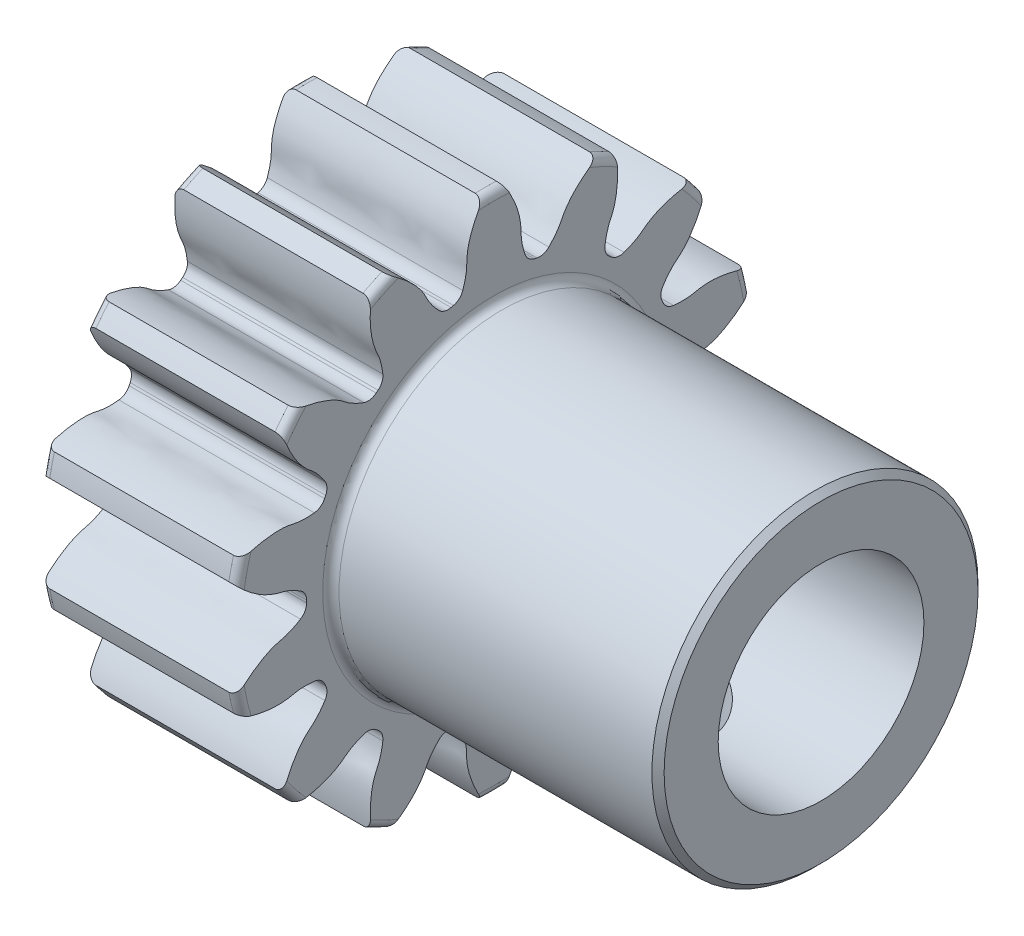
from build123d import *

# Parameters (mm, degrees)
SKETCH1_W                  = 4.7498
SKETCH1_H                  = 6.35
CUT_EXTRUDE1_DEPTH         = 5.7498
CUT_EXTRUDE2_DEPTH         = 5.7498001
CUT_EXTRUDE3_DEPTH         = 5.7498001
CUT_EXTRUDE4_DEPTH         = 5.7498001
CUT_EXTRUDE5_DEPTH         = 5.7498001
CUT_EXTRUDE6_DEPTH         = 5.7498001
CUT_EXTRUDE7_DEPTH         = 5.7498001
CUT_EXTRUDE8_DEPTH         = 5.7498001
CUT_EXTRUDE9_DEPTH         = 5.7498001
CUT_EXTRUDE10_DEPTH        = 5.7498001
CUT_EXTRUDE11_DEPTH        = 5.7498001
CUT_EXTRUDE12_DEPTH        = 5.7498001
CUT_EXTRUDE13_DEPTH        = 5.7498001
CUT_EXTRUDE14_DEPTH        = 5.7498001
SKETCH16_W                 = 7.9502
SKETCH16_H                 = 3.9624
M3_5_CLEARANCE_HOLE1_D     = 3.9624
M3_5_CLEARANCE_HOLE1_DEPTH = 12.7
CHAMFER1_SIZE              = 0.14859
FILLET1_R                  = 0.1984375
FILLET2_R                  = 0.3095625
SKETCH19_R                 = 2.5
SHAFT_WIDENING_DEPTH       = 13.7000001
SKETCH20_R                 = 1.27
SET_SCREW_HOLE_DEPTH       = 7.3500001


with BuildPart() as part:
    # Sketch1 → Revolve1 (revolve)
    with BuildSketch(Plane.XY):
        with Locations((0, 3.175)):
            Rectangle(SKETCH1_W, SKETCH1_H)
    revolve(axis=Axis((-2.3749, 0, 0), (1, 0, 0)))

    # Sketch2 → Cut-Extrude1 (cut, through all)
    with BuildSketch(Plane(origin=(2.3749, 0, 0), x_dir=(0, 0, -1), z_dir=(1, 0, 0))):
        with BuildLine():
            ThreePointArc((2.521994598, 5.827696221), (1.413007931, 6.190792242), (0.256304009, 6.344825313))
            add(Edge.make_bspline(
                [(0.816869379, 4.479071123), (0.796906852, 4.535641399), (0.776369435, 4.59201523), (0.757224936, 4.648867554), (0.704497418, 4.805449455), (0.660288083, 4.96993855), (0.661280004, 5.135156887), (0.662293342, 5.303942526), (0.638573392, 5.474877258), (0.58971746, 5.63644061), (0.536967085, 5.810882629), (0.463788824, 5.979864297), (0.376808301, 6.140011132), (0.339002487, 6.209618456), (0.29866827, 6.277894538), (0.256304009, 6.344825313)],
                knots=[-0.000178466, -0.000178466, -0.000178466, -0.000178466, 0, 0, 0, 0.000495664, 0.000495664, 0.000495664, 0.000997325, 0.000997325, 0.000997325, 0.001535785, 0.001535785, 0.001535785, 0.001769073, 0.001769073, 0.001769073, 0.001769073], degree=3))
            ThreePointArc((0.816869379, 4.479071123), (1.013126686, 4.438798038), (1.207422247, 4.389929979))
            add(Edge.make_bspline(
                [(1.207422247, 4.389929979), (1.249952785, 4.432236621), (1.292916047, 4.474116836), (1.334831943, 4.517032524), (1.450276136, 4.635230329), (1.561476514, 4.764248171), (1.632268374, 4.913535127), (1.704588732, 5.066045404), (1.80012547, 5.209760576), (1.914242855, 5.334126332), (2.037456856, 5.46840563), (2.176706589, 5.588901995), (2.32455844, 5.695449873), (2.388821788, 5.741760577), (2.454785543, 5.785774841), (2.521994598, 5.827696221)],
                knots=[-0.000178466, -0.000178466, -0.000178466, -0.000178466, 0, 0, 0, 0.000495664, 0.000495664, 0.000495664, 0.000997325, 0.000997325, 0.000997325, 0.001535785, 0.001535785, 0.001535785, 0.00176905, 0.00176905, 0.00176905, 0.00176905], degree=3))
        make_face()
    extrude(amount=-CUT_EXTRUDE1_DEPTH, mode=Mode.SUBTRACT)

    # Sketch3 → Cut-Extrude2 (cut, through all)
    with BuildSketch(Plane(origin=(2.3749, 0, 0), x_dir=(0, 0, -1), z_dir=(1, 0, 0))):
        with BuildLine():
            ThreePointArc((4.800781245, 4.156320421), (3.959160242, 4.964629914), (2.983838464, 5.605283938))
            add(Edge.make_bspline(
                [(2.983838464, 5.605283938), (2.992967169, 5.526600229), (2.999683161, 5.447585244), (3.003543536, 5.368467883), (3.014352941, 5.14693203), (2.999753258, 4.9221841), (2.955789501, 4.704785468), (2.933787316, 4.595985738), (2.898383378, 4.488724906), (2.848665705, 4.389479601), (2.782882496, 4.258164633), (2.740075221, 4.11427691), (2.715468513, 3.969482016), (2.709284574, 3.933093448), (2.703868729, 3.8965643), (2.699304131, 3.859937351), (2.691885429, 3.800408689), (2.685929314, 3.740706772), (2.679370006, 3.681077298)],
                knots=[-0.000236251, -0.000236251, -0.000236251, -0.000236251, 0, 0, 0, 0.000665398, 0.000665398, 0.000665398, 0.000998416, 0.000998416, 0.000998416, 0.001440378, 0.001440378, 0.001440378, 0.001550407, 0.001550407, 0.001550407, 0.001729205, 0.001729205, 0.001729205, 0.001729205], degree=3))
            ThreePointArc((2.679370006, 3.681077298), (2.838717893, 3.559639648), (2.992569089, 3.431309364))
            add(Edge.make_bspline(
                [(2.992569089, 3.431309364), (3.049243943, 3.450973023), (3.106123649, 3.470064732), (3.162508986, 3.490543805), (3.317804716, 3.546946989), (3.473971538, 3.614940013), (3.602525983, 3.718727476), (3.733856103, 3.82475586), (3.882287405, 3.912786919), (4.039063896, 3.975322915), (4.208337479, 4.042843831), (4.386078566, 4.090989109), (4.565517872, 4.122834916), (4.64351061, 4.136676598), (4.722038973, 4.147711478), (4.800781245, 4.156320421)],
                knots=[-0.000178466, -0.000178466, -0.000178466, -0.000178466, 0, 0, 0, 0.000495664, 0.000495664, 0.000495664, 0.000997325, 0.000997325, 0.000997325, 0.001535785, 0.001535785, 0.001535785, 0.001769052, 0.001769052, 0.001769052, 0.001769052], degree=3))
        make_face()
    extrude(amount=-CUT_EXTRUDE2_DEPTH, mode=Mode.SUBTRACT)

    # Sketch4 → Cut-Extrude3 (cut, through all)
    with BuildSketch(Plane(origin=(2.3749, 0, 0), x_dir=(0, 0, -1), z_dir=(1, 0, 0))):
        with BuildLine():
            ThreePointArc((6.128714288, 1.661734387), (5.721152311, 2.755161743), (5.120387116, 3.755547334))
            add(Edge.make_bspline(
                [(5.120387116, 3.755547334), (5.094472214, 3.680694965), (5.066239797, 3.606590964), (5.035390138, 3.533633731), (4.949008271, 3.3293468), (4.838339939, 3.133190476), (4.704404231, 2.956396236), (4.637374513, 2.867917456), (4.558937937, 2.786639979), (4.471082938, 2.718794739), (4.354838885, 2.629026306), (4.253840319, 2.517961328), (4.168846292, 2.398182086), (4.147486347, 2.36808023), (4.126757436, 2.337518452), (4.106753037, 2.306499216), (4.0742405, 2.256084599), (4.042970534, 2.204879291), (4.011188543, 2.154000969)],
                knots=[-0.000236253, -0.000236253, -0.000236253, -0.000236253, 0, 0, 0, 0.000665398, 0.000665398, 0.000665398, 0.000998416, 0.000998416, 0.000998416, 0.001440378, 0.001440378, 0.001440378, 0.001550407, 0.001550407, 0.001550407, 0.001729205, 0.001729205, 0.001729205, 0.001729205], degree=3))
            ThreePointArc((4.011188543, 2.154000969), (4.102066207, 1.97545097), (4.185000921, 1.793075847))
            add(Edge.make_bspline(
                [(4.185000921, 1.793075847), (4.244594942, 1.786201894), (4.304125369, 1.77872375), (4.363812339, 1.772710076), (4.52820138, 1.756147298), (4.698403893, 1.74964865), (4.859259138, 1.78738024), (5.02358748, 1.82592651), (5.195514707, 1.840837825), (5.363898796, 1.829158041), (5.545705252, 1.816547229), (5.726733892, 1.782805658), (5.902220498, 1.733641942), (5.978495207, 1.712273085), (6.054034673, 1.688142989), (6.128714288, 1.661734387)],
                knots=[-0.000178466, -0.000178466, -0.000178466, -0.000178466, 0, 0, 0, 0.000495664, 0.000495664, 0.000495664, 0.000997325, 0.000997325, 0.000997325, 0.001535785, 0.001535785, 0.001535785, 0.001769073, 0.001769073, 0.001769073, 0.001769073], degree=3))
        make_face()
    extrude(amount=-CUT_EXTRUDE3_DEPTH, mode=Mode.SUBTRACT)

    # Sketch5 → Cut-Extrude4 (cut, through all)
    with BuildSketch(Plane(origin=(2.3749, 0, 0), x_dir=(0, 0, -1), z_dir=(1, 0, 0))):
        with BuildLine():
            ThreePointArc((6.242780303, -1.161978522), (6.35, 0), (6.242780303, 1.161978522))
            add(Edge.make_bspline(
                [(6.242780303, 1.161978522), (6.186954558, 1.105782923), (6.129365507, 1.051267112), (6.069915968, 0.998920081), (5.903451817, 0.852343603), (5.718634057, 0.723630052), (5.521254007, 0.622456472), (5.422472815, 0.57182295), (5.316538926, 0.532626829), (5.20794736, 0.509619235), (5.064266024, 0.479177076), (4.925080173, 0.422932624), (4.796532934, 0.351892782), (4.764227583, 0.33403968), (4.732291221, 0.315498407), (4.700809139, 0.296230624), (4.649642272, 0.264915285), (4.599251857, 0.232348426), (4.548541995, 0.200298332)],
                knots=[-0.000236275, -0.000236275, -0.000236275, -0.000236275, 0, 0, 0, 0.000665398, 0.000665398, 0.000665398, 0.000998416, 0.000998416, 0.000998416, 0.001440378, 0.001440378, 0.001440378, 0.001550407, 0.001550407, 0.001550407, 0.001729205, 0.001729205, 0.001729205, 0.001729205], degree=3))
            ThreePointArc((4.548541995, 0.200298332), (4.55295, 0), (4.548541995, -0.200298332))
            add(Edge.make_bspline(
                [(4.548541995, -0.200298332), (4.599251857, -0.232348426), (4.649642272, -0.264915285), (4.700809139, -0.296230624), (4.841732227, -0.382478904), (4.992259735, -0.462182085), (5.153556426, -0.497979573), (5.318335746, -0.534549979), (5.479706602, -0.595711777), (5.626347756, -0.679294017), (5.784678087, -0.769538831), (5.933139336, -0.878484319), (6.069915968, -0.998920081), (6.129365507, -1.051267112), (6.186954558, -1.105782923), (6.242780303, -1.161978522)],
                knots=[-0.000178466, -0.000178466, -0.000178466, -0.000178466, 0, 0, 0, 0.000495664, 0.000495664, 0.000495664, 0.000997325, 0.000997325, 0.000997325, 0.001535785, 0.001535785, 0.001535785, 0.001769073, 0.001769073, 0.001769073, 0.001769073], degree=3))
        make_face()
    extrude(amount=-CUT_EXTRUDE4_DEPTH, mode=Mode.SUBTRACT)

    # Sketch6 → Cut-Extrude5 (cut, through all)
    with BuildSketch(Plane(origin=(2.3749, 0, 0), x_dir=(0, 0, -1), z_dir=(1, 0, 0))):
        with BuildLine():
            ThreePointArc((5.120387116, -3.755547334), (5.721152311, -2.755161743), (6.128714288, -1.661734387))
            add(Edge.make_bspline(
                [(6.128714288, -1.661734387), (6.054034673, -1.688142989), (5.978495207, -1.712273085), (5.902220498, -1.733641942), (5.68864433, -1.793476697), (5.466282565, -1.829254178), (5.244551714, -1.834768431), (5.133583873, -1.837528104), (5.021134177, -1.826879597), (4.913313937, -1.800492608), (4.770653168, -1.76557905), (4.620847496, -1.755863074), (4.474207404, -1.764093203), (4.437355117, -1.766161526), (4.400536693, -1.769009967), (4.363812339, -1.772710076), (4.304125369, -1.77872375), (4.244594942, -1.786201894), (4.185000921, -1.793075847)],
                knots=[-0.000236275, -0.000236275, -0.000236275, -0.000236275, 0, 0, 0, 0.000665398, 0.000665398, 0.000665398, 0.000998416, 0.000998416, 0.000998416, 0.001440378, 0.001440378, 0.001440378, 0.001550407, 0.001550407, 0.001550407, 0.001729205, 0.001729205, 0.001729205, 0.001729205], degree=3))
            ThreePointArc((4.185000921, -1.793075847), (4.102066207, -1.97545097), (4.011188543, -2.154000969))
            add(Edge.make_bspline(
                [(4.011188543, -2.154000969), (4.042970534, -2.204879291), (4.0742405, -2.256084599), (4.106753037, -2.306499216), (4.196298627, -2.445350468), (4.29733731, -2.582471991), (4.42712866, -2.684708424), (4.559722392, -2.789152289), (4.678575401, -2.914273355), (4.77442954, -3.053203563), (4.877924482, -3.203208287), (4.96441377, -3.365779702), (5.035390138, -3.533633731), (5.066239797, -3.606590964), (5.094472214, -3.680694965), (5.120387116, -3.755547334)],
                knots=[-0.000178466, -0.000178466, -0.000178466, -0.000178466, 0, 0, 0, 0.000495664, 0.000495664, 0.000495664, 0.000997325, 0.000997325, 0.000997325, 0.001535785, 0.001535785, 0.001535785, 0.001769051, 0.001769051, 0.001769051, 0.001769051], degree=3))
        make_face()
    extrude(amount=-CUT_EXTRUDE5_DEPTH, mode=Mode.SUBTRACT)

    # Sketch7 → Cut-Extrude6 (cut, through all)
    with BuildSketch(Plane(origin=(2.3749, 0, 0), x_dir=(0, 0, -1), z_dir=(1, 0, 0))):
        with BuildLine():
            ThreePointArc((2.983838464, -5.605283938), (3.959160242, -4.964629914), (4.800781245, -4.156320421))
            add(Edge.make_bspline(
                [(4.800781245, -4.156320421), (4.722038973, -4.147711478), (4.64351061, -4.136676598), (4.565517872, -4.122834916), (4.347131067, -4.084076942), (4.131266772, -4.019832184), (3.929101633, -3.928594943), (3.827925686, -3.882934181), (3.731232224, -3.824550114), (3.64553843, -3.753994809), (3.532153943, -3.660640593), (3.401399301, -3.586888555), (3.265710224, -3.530678894), (3.23161005, -3.51655278), (3.197201903, -3.503144222), (3.162508986, -3.490543805), (3.106123649, -3.470064732), (3.049243943, -3.450973023), (2.992569089, -3.431309364)],
                knots=[-0.000236252, -0.000236252, -0.000236252, -0.000236252, 0, 0, 0, 0.000665398, 0.000665398, 0.000665398, 0.000998416, 0.000998416, 0.000998416, 0.001440378, 0.001440378, 0.001440378, 0.001550407, 0.001550407, 0.001550407, 0.001729205, 0.001729205, 0.001729205, 0.001729205], degree=3))
            ThreePointArc((2.992569089, -3.431309364), (2.838717893, -3.559639648), (2.679370006, -3.681077298))
            add(Edge.make_bspline(
                [(2.679370006, -3.681077298), (2.685929314, -3.740706772), (2.691885429, -3.800408689), (2.699304131, -3.859937351), (2.719736619, -4.023890381), (2.751274528, -4.191271646), (2.823853768, -4.339697846), (2.898000098, -4.491328781), (2.950794962, -4.655627354), (2.976877, -4.822388699), (3.005038109, -5.002443057), (3.012425172, -5.186441137), (3.003543536, -5.368467883), (2.999683161, -5.447585244), (2.992967169, -5.526600229), (2.983838464, -5.605283938)],
                knots=[-0.000178466, -0.000178466, -0.000178466, -0.000178466, 0, 0, 0, 0.000495664, 0.000495664, 0.000495664, 0.000997325, 0.000997325, 0.000997325, 0.001535785, 0.001535785, 0.001535785, 0.001769051, 0.001769051, 0.001769051, 0.001769051], degree=3))
        make_face()
    extrude(amount=-CUT_EXTRUDE6_DEPTH, mode=Mode.SUBTRACT)

    # Sketch8 → Cut-Extrude7 (cut, through all)
    with BuildSketch(Plane(origin=(2.3749, 0, 0), x_dir=(0, 0, -1), z_dir=(1, 0, 0))):
        with BuildLine():
            ThreePointArc((0.256304009, -6.344825313), (1.413007931, -6.190792242), (2.521994598, -5.827696221))
            add(Edge.make_bspline(
                [(2.521994598, -5.827696221), (2.454785543, -5.785774841), (2.388821788, -5.741760577), (2.32455844, -5.695449873), (2.144615182, -5.56577566), (1.978002927, -5.414233126), (1.835444787, -5.244315046), (1.76409987, -5.159277523), (1.702313969, -5.064721575), (1.655719328, -4.963972298), (1.594068312, -4.830667371), (1.50826226, -4.707486768), (1.410399084, -4.597970329), (1.385804979, -4.570447629), (1.360622065, -4.5434378), (1.334831943, -4.517032524), (1.292916047, -4.474116836), (1.249952785, -4.432236621), (1.207422247, -4.389929979)],
                knots=[-0.000236253, -0.000236253, -0.000236253, -0.000236253, 0, 0, 0, 0.000665398, 0.000665398, 0.000665398, 0.000998416, 0.000998416, 0.000998416, 0.001440378, 0.001440378, 0.001440378, 0.001550407, 0.001550407, 0.001550407, 0.001729205, 0.001729205, 0.001729205, 0.001729205], degree=3))
            ThreePointArc((1.207422247, -4.389929979), (1.013126686, -4.438798038), (0.816869379, -4.479071123))
            add(Edge.make_bspline(
                [(0.816869379, -4.479071123), (0.796906852, -4.535641399), (0.776369435, -4.59201523), (0.757224936, -4.648867554), (0.704497418, -4.805449455), (0.660288083, -4.96993855), (0.661280004, -5.135156887), (0.662293342, -5.303942526), (0.638573392, -5.474877258), (0.58971746, -5.63644061), (0.536967085, -5.810882629), (0.463788824, -5.979864297), (0.376808301, -6.140011132), (0.339002487, -6.209618456), (0.29866827, -6.277894538), (0.256304009, -6.344825313)],
                knots=[-0.000178466, -0.000178466, -0.000178466, -0.000178466, 0, 0, 0, 0.000495664, 0.000495664, 0.000495664, 0.000997325, 0.000997325, 0.000997325, 0.001535785, 0.001535785, 0.001535785, 0.001769073, 0.001769073, 0.001769073, 0.001769073], degree=3))
        make_face()
    extrude(amount=-CUT_EXTRUDE7_DEPTH, mode=Mode.SUBTRACT)

    # Sketch9 → Cut-Extrude8 (cut, through all)
    with BuildSketch(Plane(origin=(2.3749, 0, 0), x_dir=(0, 0, -1), z_dir=(1, 0, 0))):
        with BuildLine():
            ThreePointArc((-2.521994598, -5.827696221), (-1.413007931, -6.190792242), (-0.256304009, -6.344825313))
            add(Edge.make_bspline(
                [(-0.256304009, -6.344825313), (-0.29866827, -6.277894538), (-0.339002487, -6.209618456), (-0.376808301, -6.140011132), (-0.482668042, -5.94510425), (-0.567028655, -5.736278797), (-0.62174441, -5.521334237), (-0.64912756, -5.413762677), (-0.663768445, -5.301762814), (-0.662035293, -5.190774195), (-0.659742099, -5.043921232), (-0.68360462, -4.895709492), (-0.724258893, -4.75457735), (-0.734475764, -4.719109272), (-0.745445659, -4.6838478), (-0.757224936, -4.648867554), (-0.776369435, -4.59201523), (-0.796906852, -4.535641399), (-0.816869379, -4.479071123)],
                knots=[-0.000236275, -0.000236275, -0.000236275, -0.000236275, 0, 0, 0, 0.000665398, 0.000665398, 0.000665398, 0.000998416, 0.000998416, 0.000998416, 0.001440378, 0.001440378, 0.001440378, 0.001550407, 0.001550407, 0.001550407, 0.001729205, 0.001729205, 0.001729205, 0.001729205], degree=3))
            ThreePointArc((-0.816869379, -4.479071123), (-1.013126686, -4.438798038), (-1.207422247, -4.389929979))
            add(Edge.make_bspline(
                [(-1.207422247, -4.389929979), (-1.249952785, -4.432236621), (-1.292916047, -4.474116836), (-1.334831943, -4.517032524), (-1.450276136, -4.635230329), (-1.561476514, -4.764248171), (-1.632268374, -4.913535127), (-1.704588732, -5.066045404), (-1.80012547, -5.209760576), (-1.914242855, -5.334126332), (-2.037456856, -5.46840563), (-2.176706589, -5.588901995), (-2.32455844, -5.695449873), (-2.388821788, -5.741760577), (-2.454785543, -5.785774841), (-2.521994598, -5.827696221)],
                knots=[-0.000178466, -0.000178466, -0.000178466, -0.000178466, 0, 0, 0, 0.000495664, 0.000495664, 0.000495664, 0.000997325, 0.000997325, 0.000997325, 0.001535785, 0.001535785, 0.001535785, 0.00176905, 0.00176905, 0.00176905, 0.00176905], degree=3))
        make_face()
    extrude(amount=-CUT_EXTRUDE8_DEPTH, mode=Mode.SUBTRACT)

    # Sketch10 → Cut-Extrude9 (cut, through all)
    with BuildSketch(Plane(origin=(2.3749, 0, 0), x_dir=(0, 0, -1), z_dir=(1, 0, 0))):
        with BuildLine():
            ThreePointArc((-4.800781245, -4.156320421), (-3.959160242, -4.964629914), (-2.983838464, -5.605283938))
            add(Edge.make_bspline(
                [(-2.983838464, -5.605283938), (-2.992967169, -5.526600229), (-2.999683161, -5.447585244), (-3.003543536, -5.368467884), (-3.014352941, -5.14693203), (-2.999753258, -4.9221841), (-2.955789501, -4.704785468), (-2.933787316, -4.595985738), (-2.898383378, -4.488724906), (-2.848665705, -4.389479601), (-2.782882496, -4.258164633), (-2.740075221, -4.11427691), (-2.715468513, -3.969482016), (-2.709284574, -3.933093448), (-2.703868729, -3.8965643), (-2.699304131, -3.859937351), (-2.691885429, -3.800408689), (-2.685929314, -3.740706772), (-2.679370006, -3.681077298)],
                knots=[-0.000236251, -0.000236251, -0.000236251, -0.000236251, 0, 0, 0, 0.000665398, 0.000665398, 0.000665398, 0.000998416, 0.000998416, 0.000998416, 0.001440378, 0.001440378, 0.001440378, 0.001550407, 0.001550407, 0.001550407, 0.001729205, 0.001729205, 0.001729205, 0.001729205], degree=3))
            ThreePointArc((-2.679370006, -3.681077298), (-2.838717893, -3.559639648), (-2.992569089, -3.431309364))
            add(Edge.make_bspline(
                [(-2.992569089, -3.431309364), (-3.049243943, -3.450973023), (-3.106123649, -3.470064732), (-3.162508986, -3.490543805), (-3.317804716, -3.546946989), (-3.473971538, -3.614940013), (-3.602525983, -3.718727476), (-3.733856103, -3.82475586), (-3.882287405, -3.912786919), (-4.039063896, -3.975322915), (-4.208337479, -4.042843831), (-4.386078566, -4.090989109), (-4.565517872, -4.122834916), (-4.64351061, -4.136676598), (-4.722038973, -4.147711478), (-4.800781245, -4.156320421)],
                knots=[-0.000178466, -0.000178466, -0.000178466, -0.000178466, 0, 0, 0, 0.000495664, 0.000495664, 0.000495664, 0.000997325, 0.000997325, 0.000997325, 0.001535785, 0.001535785, 0.001535785, 0.001769052, 0.001769052, 0.001769052, 0.001769052], degree=3))
        make_face()
    extrude(amount=-CUT_EXTRUDE9_DEPTH, mode=Mode.SUBTRACT)

    # Sketch11 → Cut-Extrude10 (cut, through all)
    with BuildSketch(Plane(origin=(2.3749, 0, 0), x_dir=(0, 0, -1), z_dir=(1, 0, 0))):
        with BuildLine():
            ThreePointArc((-6.128714288, -1.661734387), (-5.721152311, -2.755161743), (-5.120387116, -3.755547334))
            add(Edge.make_bspline(
                [(-5.120387116, -3.755547334), (-5.094472214, -3.680694965), (-5.066239797, -3.606590964), (-5.035390138, -3.533633731), (-4.949008271, -3.3293468), (-4.838339939, -3.133190476), (-4.704404231, -2.956396236), (-4.637374513, -2.867917456), (-4.558937937, -2.786639979), (-4.471082938, -2.718794739), (-4.354838885, -2.629026306), (-4.253840319, -2.517961328), (-4.168846292, -2.398182086), (-4.147486347, -2.36808023), (-4.126757436, -2.337518452), (-4.106753037, -2.306499216), (-4.0742405, -2.256084599), (-4.042970534, -2.204879291), (-4.011188543, -2.154000969)],
                knots=[-0.000236253, -0.000236253, -0.000236253, -0.000236253, 0, 0, 0, 0.000665398, 0.000665398, 0.000665398, 0.000998416, 0.000998416, 0.000998416, 0.001440378, 0.001440378, 0.001440378, 0.001550407, 0.001550407, 0.001550407, 0.001729205, 0.001729205, 0.001729205, 0.001729205], degree=3))
            ThreePointArc((-4.011188543, -2.154000969), (-4.102066207, -1.97545097), (-4.185000921, -1.793075847))
            add(Edge.make_bspline(
                [(-4.185000921, -1.793075847), (-4.244594942, -1.786201894), (-4.304125369, -1.77872375), (-4.363812339, -1.772710076), (-4.528201381, -1.756147297), (-4.698403893, -1.74964865), (-4.859259138, -1.78738024), (-5.02358748, -1.82592651), (-5.195514707, -1.840837825), (-5.363898796, -1.829158041), (-5.545705252, -1.816547229), (-5.726733892, -1.782805658), (-5.902220498, -1.733641942), (-5.978495207, -1.712273085), (-6.054034673, -1.688142989), (-6.128714288, -1.661734387)],
                knots=[-0.000178466, -0.000178466, -0.000178466, -0.000178466, 0, 0, 0, 0.000495664, 0.000495664, 0.000495664, 0.000997325, 0.000997325, 0.000997325, 0.001535785, 0.001535785, 0.001535785, 0.001769073, 0.001769073, 0.001769073, 0.001769073], degree=3))
        make_face()
    extrude(amount=-CUT_EXTRUDE10_DEPTH, mode=Mode.SUBTRACT)

    # Sketch12 → Cut-Extrude11 (cut, through all)
    with BuildSketch(Plane(origin=(2.3749, 0, 0), x_dir=(0, 0, -1), z_dir=(1, 0, 0))):
        with BuildLine():
            ThreePointArc((-6.242780303, 1.161978522), (-6.35, 0), (-6.242780303, -1.161978522))
            add(Edge.make_bspline(
                [(-6.242780303, -1.161978522), (-6.186954558, -1.105782923), (-6.129365507, -1.051267112), (-6.069915968, -0.998920081), (-5.903451817, -0.852343603), (-5.718634057, -0.723630052), (-5.521254007, -0.622456472), (-5.422472815, -0.57182295), (-5.316538926, -0.532626829), (-5.20794736, -0.509619235), (-5.064266024, -0.479177076), (-4.925080173, -0.422932624), (-4.796532934, -0.351892782), (-4.764227583, -0.33403968), (-4.732291221, -0.315498407), (-4.700809139, -0.296230624), (-4.649642272, -0.264915285), (-4.599251857, -0.232348426), (-4.548541995, -0.200298332)],
                knots=[-0.000236275, -0.000236275, -0.000236275, -0.000236275, 0, 0, 0, 0.000665398, 0.000665398, 0.000665398, 0.000998416, 0.000998416, 0.000998416, 0.001440378, 0.001440378, 0.001440378, 0.001550407, 0.001550407, 0.001550407, 0.001729205, 0.001729205, 0.001729205, 0.001729205], degree=3))
            ThreePointArc((-4.548541995, -0.200298332), (-4.55295, 0), (-4.548541995, 0.200298332))
            add(Edge.make_bspline(
                [(-4.548541995, 0.200298332), (-4.599251857, 0.232348426), (-4.649642272, 0.264915285), (-4.700809139, 0.296230624), (-4.841732227, 0.382478904), (-4.992259735, 0.462182085), (-5.153556426, 0.497979573), (-5.318335746, 0.534549979), (-5.479706602, 0.595711777), (-5.626347756, 0.679294017), (-5.784678087, 0.769538831), (-5.933139336, 0.878484319), (-6.069915968, 0.998920081), (-6.129365507, 1.051267112), (-6.186954558, 1.105782923), (-6.242780303, 1.161978522)],
                knots=[-0.000178466, -0.000178466, -0.000178466, -0.000178466, 0, 0, 0, 0.000495664, 0.000495664, 0.000495664, 0.000997325, 0.000997325, 0.000997325, 0.001535785, 0.001535785, 0.001535785, 0.001769073, 0.001769073, 0.001769073, 0.001769073], degree=3))
        make_face()
    extrude(amount=-CUT_EXTRUDE11_DEPTH, mode=Mode.SUBTRACT)

    # Sketch13 → Cut-Extrude12 (cut, through all)
    with BuildSketch(Plane(origin=(2.3749, 0, 0), x_dir=(0, 0, -1), z_dir=(1, 0, 0))):
        with BuildLine():
            ThreePointArc((-5.120387116, 3.755547334), (-5.721152311, 2.755161743), (-6.128714288, 1.661734387))
            add(Edge.make_bspline(
                [(-6.128714288, 1.661734387), (-6.054034673, 1.688142989), (-5.978495207, 1.712273085), (-5.902220498, 1.733641942), (-5.68864433, 1.793476697), (-5.466282565, 1.829254178), (-5.244551714, 1.834768431), (-5.133583873, 1.837528104), (-5.021134177, 1.826879597), (-4.913313937, 1.800492608), (-4.770653168, 1.76557905), (-4.620847496, 1.755863074), (-4.474207404, 1.764093203), (-4.437355117, 1.766161526), (-4.400536693, 1.769009967), (-4.363812339, 1.772710076), (-4.304125369, 1.77872375), (-4.244594942, 1.786201894), (-4.185000921, 1.793075847)],
                knots=[-0.000236275, -0.000236275, -0.000236275, -0.000236275, 0, 0, 0, 0.000665398, 0.000665398, 0.000665398, 0.000998416, 0.000998416, 0.000998416, 0.001440378, 0.001440378, 0.001440378, 0.001550407, 0.001550407, 0.001550407, 0.001729205, 0.001729205, 0.001729205, 0.001729205], degree=3))
            ThreePointArc((-4.185000921, 1.793075847), (-4.102066207, 1.97545097), (-4.011188543, 2.154000969))
            add(Edge.make_bspline(
                [(-4.011188543, 2.154000969), (-4.042970534, 2.204879291), (-4.0742405, 2.256084599), (-4.106753037, 2.306499216), (-4.196298627, 2.445350468), (-4.29733731, 2.582471991), (-4.42712866, 2.684708424), (-4.559722392, 2.789152289), (-4.678575401, 2.914273355), (-4.77442954, 3.053203563), (-4.877924482, 3.203208287), (-4.96441377, 3.365779702), (-5.035390138, 3.533633731), (-5.066239797, 3.606590964), (-5.094472214, 3.680694965), (-5.120387116, 3.755547334)],
                knots=[-0.000178466, -0.000178466, -0.000178466, -0.000178466, 0, 0, 0, 0.000495664, 0.000495664, 0.000495664, 0.000997325, 0.000997325, 0.000997325, 0.001535785, 0.001535785, 0.001535785, 0.001769051, 0.001769051, 0.001769051, 0.001769051], degree=3))
        make_face()
    extrude(amount=-CUT_EXTRUDE12_DEPTH, mode=Mode.SUBTRACT)

    # Sketch14 → Cut-Extrude13 (cut, through all)
    with BuildSketch(Plane(origin=(2.3749, 0, 0), x_dir=(0, 0, -1), z_dir=(1, 0, 0))):
        with BuildLine():
            ThreePointArc((-2.983838464, 5.605283938), (-3.959160242, 4.964629914), (-4.800781245, 4.156320421))
            add(Edge.make_bspline(
                [(-4.800781245, 4.156320421), (-4.722038973, 4.147711478), (-4.64351061, 4.136676598), (-4.565517872, 4.122834916), (-4.347131067, 4.084076942), (-4.131266772, 4.019832184), (-3.929101633, 3.928594943), (-3.827925686, 3.882934181), (-3.731232224, 3.824550114), (-3.64553843, 3.753994809), (-3.532153943, 3.660640593), (-3.401399301, 3.586888555), (-3.265710224, 3.530678894), (-3.23161005, 3.51655278), (-3.197201903, 3.503144222), (-3.162508986, 3.490543805), (-3.106123649, 3.470064732), (-3.049243943, 3.450973023), (-2.992569089, 3.431309364)],
                knots=[-0.000236252, -0.000236252, -0.000236252, -0.000236252, 0, 0, 0, 0.000665398, 0.000665398, 0.000665398, 0.000998416, 0.000998416, 0.000998416, 0.001440378, 0.001440378, 0.001440378, 0.001550407, 0.001550407, 0.001550407, 0.001729205, 0.001729205, 0.001729205, 0.001729205], degree=3))
            ThreePointArc((-2.992569089, 3.431309364), (-2.838717893, 3.559639648), (-2.679370006, 3.681077298))
            add(Edge.make_bspline(
                [(-2.679370006, 3.681077298), (-2.685929314, 3.740706772), (-2.691885429, 3.800408689), (-2.699304131, 3.859937351), (-2.719736619, 4.023890381), (-2.751274528, 4.191271646), (-2.823853768, 4.339697846), (-2.898000098, 4.491328781), (-2.950794962, 4.655627354), (-2.976877, 4.822388699), (-3.005038109, 5.002443057), (-3.012425172, 5.186441137), (-3.003543536, 5.368467883), (-2.999683161, 5.447585244), (-2.992967169, 5.526600229), (-2.983838464, 5.605283938)],
                knots=[-0.000178466, -0.000178466, -0.000178466, -0.000178466, 0, 0, 0, 0.000495664, 0.000495664, 0.000495664, 0.000997325, 0.000997325, 0.000997325, 0.001535785, 0.001535785, 0.001535785, 0.001769051, 0.001769051, 0.001769051, 0.001769051], degree=3))
        make_face()
    extrude(amount=-CUT_EXTRUDE13_DEPTH, mode=Mode.SUBTRACT)

    # Sketch15 → Cut-Extrude14 (cut, through all)
    with BuildSketch(Plane(origin=(2.3749, 0, 0), x_dir=(0, 0, -1), z_dir=(1, 0, 0))):
        with BuildLine():
            ThreePointArc((-0.256304009, 6.344825313), (-1.413007931, 6.190792242), (-2.521994598, 5.827696221))
            add(Edge.make_bspline(
                [(-2.521994598, 5.827696221), (-2.454785543, 5.785774841), (-2.388821788, 5.741760577), (-2.32455844, 5.695449873), (-2.144615182, 5.56577566), (-1.978002927, 5.414233126), (-1.835444787, 5.244315046), (-1.76409987, 5.159277523), (-1.702313969, 5.064721575), (-1.655719328, 4.963972298), (-1.594068312, 4.830667371), (-1.50826226, 4.707486768), (-1.410399084, 4.597970329), (-1.385804979, 4.570447629), (-1.360622065, 4.5434378), (-1.334831943, 4.517032524), (-1.292916047, 4.474116836), (-1.249952785, 4.432236621), (-1.207422247, 4.389929979)],
                knots=[-0.000236253, -0.000236253, -0.000236253, -0.000236253, 0, 0, 0, 0.000665398, 0.000665398, 0.000665398, 0.000998416, 0.000998416, 0.000998416, 0.001440378, 0.001440378, 0.001440378, 0.001550407, 0.001550407, 0.001550407, 0.001729205, 0.001729205, 0.001729205, 0.001729205], degree=3))
            ThreePointArc((-1.207422247, 4.389929979), (-1.013126686, 4.438798038), (-0.816869379, 4.479071123))
            add(Edge.make_bspline(
                [(-0.816869379, 4.479071123), (-0.796906852, 4.535641399), (-0.776369435, 4.59201523), (-0.757224936, 4.648867554), (-0.704497418, 4.805449455), (-0.660288083, 4.96993855), (-0.661280004, 5.135156887), (-0.662293342, 5.303942526), (-0.638573392, 5.474877258), (-0.58971746, 5.63644061), (-0.536967085, 5.810882629), (-0.463788824, 5.979864297), (-0.376808301, 6.140011132), (-0.339002487, 6.209618456), (-0.29866827, 6.277894538), (-0.256304009, 6.344825313)],
                knots=[-0.000178466, -0.000178466, -0.000178466, -0.000178466, 0, 0, 0, 0.000495664, 0.000495664, 0.000495664, 0.000997325, 0.000997325, 0.000997325, 0.001535785, 0.001535785, 0.001535785, 0.001769073, 0.001769073, 0.001769073, 0.001769073], degree=3))
        make_face()
    extrude(amount=-CUT_EXTRUDE14_DEPTH, mode=Mode.SUBTRACT)

    # Sketch16 → Revolve2 (revolve)
    with BuildSketch(Plane.XY):
        with Locations((6.35, 1.9812)):
            Rectangle(SKETCH16_W, SKETCH16_H)
    revolve(axis=Axis((2.3749, 0, 0), (1, 0, 0)))

    # M3.5 Clearance Hole1
    with Locations(Plane(origin=(10.3251, 0, 0), x_dir=(0, 0, -1), z_dir=(1, 0, 0))):
        with Locations((0, 0)):
            Hole(M3_5_CLEARANCE_HOLE1_D / 2, depth=M3_5_CLEARANCE_HOLE1_DEPTH)

    # Chamfer1
    chamfer1_edges = [part.edges().sort_by_distance(p)[0] for p in [
        (10.3251, -3.9624, 0),
        (10.3251, 0, -1.9812),
        (-2.3749, 0, -1.9812),
    ]]
    chamfer(chamfer1_edges, length=CHAMFER1_SIZE)

    # Fillet1
    fillet1_edges = [part.edges().sort_by_distance(p)[0] for p in [
        (-2.3749, 6.35, 0),
        (2.3749, -5.721152311, -2.755161743),
        (2.3749, -1.413007931, 6.190792242),
        (-2.3749, 5.721152311, 2.755161743),
        (2.3749, 3.959160242, -4.964629914),
        (-2.3749, 3.959160242, 4.964629914),
        (2.3749, 3.959160242, 4.964629914),
        (-2.3749, 1.413007931, 6.190792242),
        (2.3749, -5.721152311, 2.755161743),
        (-2.3749, -1.413007931, 6.190792242),
        (2.3749, -1.413007931, -6.190792242),
        (-2.3749, -3.959160242, 4.964629914),
        (2.3749, -3.9624, 0),
        (-2.3749, -5.721152311, 2.755161743),
        (2.3749, 5.721152311, 2.755161743),
        (-2.3749, -6.35, 0),
        (2.3749, 1.413007931, 6.190792242),
        (-2.3749, -5.721152311, -2.755161743),
        (2.3749, -3.959160242, 4.964629914),
        (-2.3749, -3.959160242, -4.964629914),
        (2.3749, -6.35, 0),
        (-2.3749, -1.413007931, -6.190792242),
        (2.3749, -3.959160242, -4.964629914),
        (-2.3749, 1.413007931, -6.190792242),
        (2.3749, 1.413007931, -6.190792242),
        (-2.3749, 3.959160242, -4.964629914),
        (2.3749, 5.721152311, -2.755161743),
        (2.3749, 6.35, 0),
        (-2.3749, 5.721152311, -2.755161743),
    ]]
    fillet(fillet1_edges, radius=FILLET1_R)

    # Fillet2
    fillet2_edges = [part.edges().sort_by_distance(p)[0] for p in [
        (0, -0.200298332, -4.548541995),
        (0, 3.431309364, -2.992569089),
        (0, 1.793075847, -4.185000921),
        (0, -4.479071123, 0.816869379),
        (0, 4.479071123, -0.816869379),
        (0, -4.389929979, 1.207422247),
        (0, 1.793075847, 4.185000921),
        (0, -4.479071123, -0.816869379),
        (0, 3.431309364, 2.992569089),
        (0, -4.389929979, -1.207422247),
        (0, 4.389929979, 1.207422247),
        (0, -3.681077298, 2.679370006),
        (0, 0.200298332, 4.548541995),
        (0, -3.431309364, 2.992569089),
        (0, 0.200298332, -4.548541995),
        (0, -3.681077298, -2.679370006),
        (0, 2.154000969, 4.011188543),
        (0, -3.431309364, -2.992569089),
        (0, 2.154000969, -4.011188543),
        (0, -2.154000969, 4.011188543),
        (0, 3.681077298, 2.679370006),
        (0, -1.793075847, 4.185000921),
        (0, 3.681077298, -2.679370006),
        (0, -2.154000969, -4.011188543),
        (0, 4.479071123, 0.816869379),
        (0, -1.793075847, -4.185000921),
        (0, -0.200298332, 4.548541995),
        (0, 4.389929979, -1.207422247),
    ]]
    fillet(fillet2_edges, radius=FILLET2_R)

    # Sketch19 → Shaft widening (cut, through all)
    with BuildSketch(Plane(origin=(10.3251, 0, 0), x_dir=(0, 0, -1), z_dir=(1, 0, 0))):
        Circle(SKETCH19_R)
    extrude(amount=-SHAFT_WIDENING_DEPTH, mode=Mode.SUBTRACT)

    # Sketch20 → Set screw hole (cut, through all)
    with BuildSketch(Plane(origin=(0, 0, 0), x_dir=(1, 0, 0), z_dir=(0, 1, 0))):
        with Locations((6.37492375, 0)):
            Circle(SKETCH20_R)
    extrude(amount=-SET_SCREW_HOLE_DEPTH, mode=Mode.SUBTRACT)


solid = part.part
